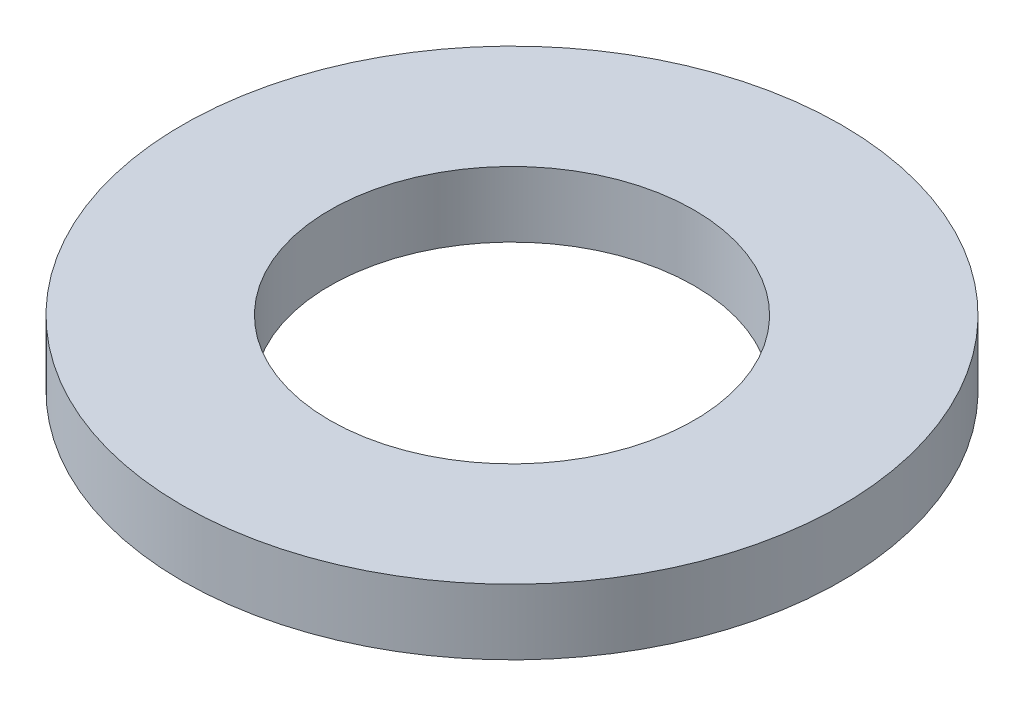
from build123d import *

# Parameters (mm, degrees)
SKETCH1_R           = 18.6563
BOSS_EXTRUDE1_DEPTH = 3.7084
SKETCH5_R           = 10.3124
CUT_EXTRUDE1_DEPTH  = 4.7084


with BuildPart() as part:
    # Sketch1 → Boss-Extrude1 (new body)
    with BuildSketch(Plane(origin=(0, 0, 0), x_dir=(1, 0, 0), z_dir=(0, 1, 0))):
        Circle(SKETCH1_R)
    extrude(amount=BOSS_EXTRUDE1_DEPTH)

    # Sketch5 → Cut-Extrude1 (cut, through all)
    with BuildSketch(Plane(origin=(0, 3.7084, 0), x_dir=(-1, 0, 0), z_dir=(0, 1, 0))):
        Circle(SKETCH5_R)
    extrude(amount=-CUT_EXTRUDE1_DEPTH, mode=Mode.SUBTRACT)


solid = part.part
